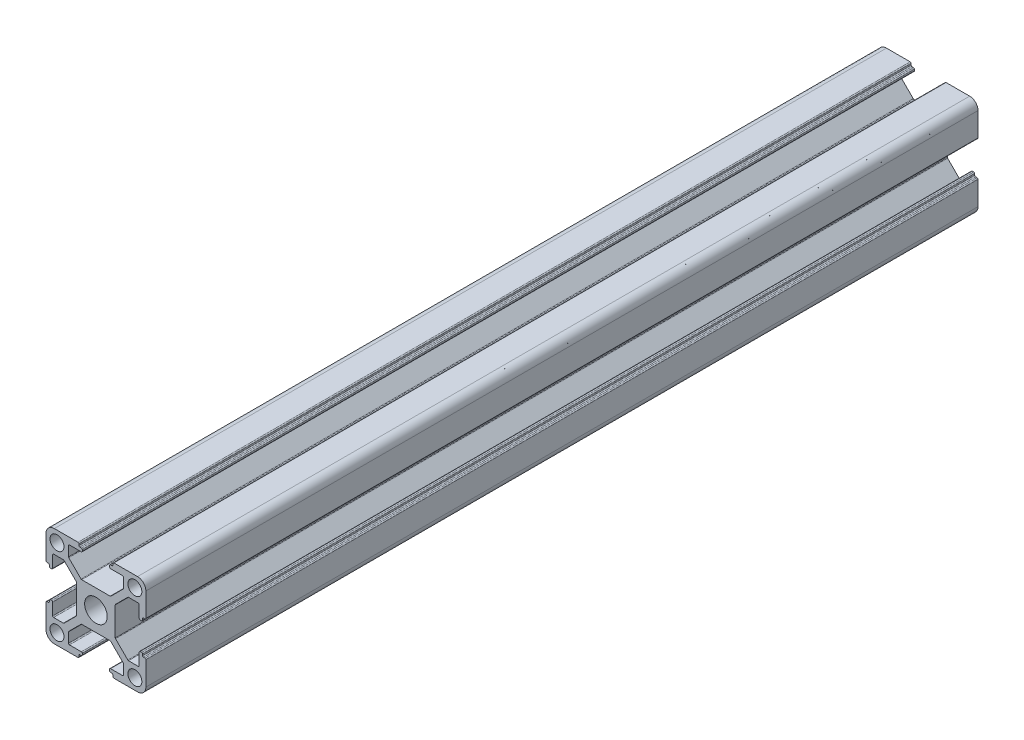
from build123d import *

# Parameters (mm, degrees)
CROQUIS1_R              = 2.1
CROQUIS1_R_2            = 3.4
SALIENTE_EXTRUIR1_DEPTH = 400
CROQUIS3_W              = 36.891585518
CROQUIS3_H              = 31.857253434
CORTAR_EXTRUIR2_DEPTH   = 150


with BuildPart() as part:
    # Croquis1 → Saliente-Extruir1 (new body)
    with BuildSketch(Plane(origin=(0, 0, -50), x_dir=(-1, 0, 0), z_dir=(0, 0, -1))):
        with BuildLine():
            Line((14.7, -5.1), (14.3, -5.1))
            ThreePointArc((14.3, -5.1), (14.087867966, -5.012132034), (14, -4.8))
            Line((14, -4.8), (14, -4.4))
            ThreePointArc((14, -4.4), (13.912132034, -4.187867966), (13.7, -4.1))
            Line((13.7, -4.1), (13.3, -4.1))
            ThreePointArc((13.3, -4.1), (13.087867966, -4.187867966), (13, -4.4))
            Line((13, -4.4), (13, -7.95))
            ThreePointArc((13, -7.95), (12.912132034, -8.162132034), (12.7, -8.25))
            Line((12.7, -8.25), (9.789264108, -8.25))
            ThreePointArc((9.789264108, -8.25), (9.674477865, -8.22717164), (9.577160832, -8.162160788))
            Line((9.577160832, -8.162160788), (5.887896723, -4.473896751))
            ThreePointArc((5.887896723, -4.473896751), (5.822843922, -4.376559778), (5.8, -4.261735963))
            Line((5.8, -4.261735963), (5.8, 4.260735931))
            ThreePointArc((5.8, 4.260735931), (5.82283614, 4.375540961), (5.887867966, 4.472867966))
            Line((5.887867966, 4.472867966), (9.577132034, 8.162132034))
            ThreePointArc((9.577132034, 8.162132034), (9.674459039, 8.22716386), (9.789264069, 8.25))
            Line((9.789264069, 8.25), (12.7, 8.25))
            ThreePointArc((12.7, 8.25), (12.912132034, 8.162132034), (13, 7.95))
            Line((13, 7.95), (13, 4.4))
            ThreePointArc((13, 4.4), (13.087867966, 4.187867966), (13.3, 4.1))
            Line((13.3, 4.1), (13.7, 4.1))
            ThreePointArc((13.7, 4.1), (13.912132034, 4.187867966), (14, 4.4))
            Line((14, 4.4), (14, 4.8))
            ThreePointArc((14, 4.8), (14.087867966, 5.012132034), (14.3, 5.1))
            Line((14.3, 5.1), (14.7, 5.1))
            ThreePointArc((14.7, 5.1), (14.912132034, 5.187867966), (15, 5.4))
            Line((15, 5.4), (15, 12.5))
            ThreePointArc((15, 12.5), (14.267766953, 14.267766953), (12.5, 15))
            Line((12.5, 15), (5.4, 15))
            ThreePointArc((5.4, 15), (5.187867966, 14.912132034), (5.1, 14.7))
            Line((5.1, 14.7), (5.1, 14.3))
            ThreePointArc((5.1, 14.3), (5.012132034, 14.087867966), (4.8, 14))
            Line((4.8, 14), (4.4, 14))
            ThreePointArc((4.4, 14), (4.187867966, 13.912132034), (4.1, 13.7))
            Line((4.1, 13.7), (4.1, 13.3))
            ThreePointArc((4.1, 13.3), (4.187867966, 13.087867966), (4.4, 13))
            Line((4.4, 13), (7.95, 13))
            ThreePointArc((7.95, 13), (8.162132034, 12.912132034), (8.25, 12.7))
            Line((8.25, 12.7), (8.25, 9.788264069))
            ThreePointArc((8.25, 9.788264069), (8.22716386, 9.673459039), (8.162132034, 9.576132034))
            Line((8.162132034, 9.576132034), (4.473867966, 5.887867966))
            ThreePointArc((4.473867966, 5.887867966), (4.376540961, 5.82283614), (4.261735931, 5.8))
            Line((4.261735931, 5.8), (-4.260735892, 5.8))
            ThreePointArc((-4.260735892, 5.8), (-4.375522135, 5.82282836), (-4.472839168, 5.887839212))
            Line((-4.472839168, 5.887839212), (-8.162103277, 9.576103249))
            ThreePointArc((-8.162103277, 9.576103249), (-8.227156078, 9.673440222), (-8.25, 9.788264037))
            Line((-8.25, 9.788264037), (-8.25, 12.7))
            ThreePointArc((-8.25, 12.7), (-8.162132034, 12.912132034), (-7.95, 13))
            Line((-7.95, 13), (-4.4, 13))
            ThreePointArc((-4.4, 13), (-4.187867966, 13.087867966), (-4.1, 13.3))
            Line((-4.1, 13.3), (-4.1, 13.7))
            ThreePointArc((-4.1, 13.7), (-4.187867966, 13.912132034), (-4.4, 14))
            Line((-4.4, 14), (-4.8, 14))
            ThreePointArc((-4.8, 14), (-5.012132034, 14.087867966), (-5.1, 14.3))
            Line((-5.1, 14.3), (-5.1, 14.7))
            ThreePointArc((-5.1, 14.7), (-5.187867966, 14.912132034), (-5.4, 15))
            Line((-5.4, 15), (-12.5, 15))
            ThreePointArc((-12.5, 15), (-14.267766953, 14.267766953), (-15, 12.5))
            Line((-15, 12.5), (-15, 5.4))
            ThreePointArc((-15, 5.4), (-14.912132034, 5.187867966), (-14.7, 5.1))
            Line((-14.7, 5.1), (-14.3, 5.1))
            ThreePointArc((-14.3, 5.1), (-14.087867966, 5.012132034), (-14, 4.8))
            Line((-14, 4.8), (-14, 4.4))
            ThreePointArc((-14, 4.4), (-13.912132034, 4.187867966), (-13.7, 4.1))
            Line((-13.7, 4.1), (-13.3, 4.1))
            ThreePointArc((-13.3, 4.1), (-13.087867966, 4.187867966), (-13, 4.4))
            Line((-13, 4.4), (-13, 7.95))
            ThreePointArc((-13, 7.95), (-12.912132034, 8.162132034), (-12.7, 8.25))
            Line((-12.7, 8.25), (-9.788264037, 8.25))
            ThreePointArc((-9.788264037, 8.25), (-9.673440222, 8.227156078), (-9.576103249, 8.162103277))
            Line((-9.576103249, 8.162103277), (-5.887839212, 4.472839168))
            ThreePointArc((-5.887839212, 4.472839168), (-5.82282836, 4.375522135), (-5.8, 4.260735892))
            Line((-5.8, 4.260735892), (-5.8, -4.261735931))
            ThreePointArc((-5.8, -4.261735931), (-5.82283614, -4.376540961), (-5.887867966, -4.473867966))
            Line((-5.887867966, -4.473867966), (-9.576132034, -8.162132034))
            ThreePointArc((-9.576132034, -8.162132034), (-9.673459039, -8.22716386), (-9.788264069, -8.25))
            Line((-9.788264069, -8.25), (-12.7, -8.25))
            ThreePointArc((-12.7, -8.25), (-12.912132034, -8.162132034), (-13, -7.95))
            Line((-13, -7.95), (-13, -4.4))
            ThreePointArc((-13, -4.4), (-13.087867966, -4.187867966), (-13.3, -4.1))
            Line((-13.3, -4.1), (-13.7, -4.1))
            ThreePointArc((-13.7, -4.1), (-13.912132034, -4.187867966), (-14, -4.4))
            Line((-14, -4.4), (-14, -4.8))
            ThreePointArc((-14, -4.8), (-14.087867966, -5.012132034), (-14.3, -5.1))
            Line((-14.3, -5.1), (-14.7, -5.1))
            ThreePointArc((-14.7, -5.1), (-14.912132034, -5.187867966), (-15, -5.4))
            Line((-15, -5.4), (-15, -12.5))
            ThreePointArc((-15, -12.5), (-14.267766953, -14.267766953), (-12.5, -15))
            Line((-12.5, -15), (-5.4, -15))
            ThreePointArc((-5.4, -15), (-5.187867966, -14.912132034), (-5.1, -14.7))
            Line((-5.1, -14.7), (-5.1, -14.3))
            ThreePointArc((-5.1, -14.3), (-5.012132034, -14.087867966), (-4.8, -14))
            Line((-4.8, -14), (-4.4, -14))
            ThreePointArc((-4.4, -14), (-4.187867966, -13.912132034), (-4.1, -13.7))
            Line((-4.1, -13.7), (-4.1, -13.3))
            ThreePointArc((-4.1, -13.3), (-4.187867966, -13.087867966), (-4.4, -13))
            Line((-4.4, -13), (-7.95, -13))
            ThreePointArc((-7.95, -13), (-8.162132034, -12.912132034), (-8.25, -12.7))
            Line((-8.25, -12.7), (-8.25, -9.789264069))
            ThreePointArc((-8.25, -9.789264069), (-8.22716386, -9.674459039), (-8.162132034, -9.577132034))
            Line((-8.162132034, -9.577132034), (-4.472867966, -5.887867966))
            ThreePointArc((-4.472867966, -5.887867966), (-4.375540961, -5.82283614), (-4.260735931, -5.8))
            Line((-4.260735931, -5.8), (4.261735963, -5.8))
            ThreePointArc((4.261735963, -5.8), (4.376559778, -5.822843922), (4.473896751, -5.887896723))
            Line((4.473896751, -5.887896723), (8.162160788, -9.577160832))
            ThreePointArc((8.162160788, -9.577160832), (8.22717164, -9.674477865), (8.25, -9.789264108))
            Line((8.25, -9.789264108), (8.25, -12.7))
            ThreePointArc((8.25, -12.7), (8.162132034, -12.912132034), (7.95, -13))
            Line((7.95, -13), (4.4, -13))
            ThreePointArc((4.4, -13), (4.187867966, -13.087867966), (4.1, -13.3))
            Line((4.1, -13.3), (4.1, -13.7))
            ThreePointArc((4.1, -13.7), (4.187867966, -13.912132034), (4.4, -14))
            Line((4.4, -14), (4.8, -14))
            ThreePointArc((4.8, -14), (5.012132034, -14.087867966), (5.1, -14.3))
            Line((5.1, -14.3), (5.1, -14.7))
            ThreePointArc((5.1, -14.7), (5.187867966, -14.912132034), (5.4, -15))
            Line((5.4, -15), (12.5, -15))
            ThreePointArc((12.5, -15), (14.267766953, -14.267766953), (15, -12.5))
            Line((15, -12.5), (15, -5.4))
            ThreePointArc((15, -5.4), (14.912132034, -5.187867966), (14.7, -5.1))
        make_face()
        with Locations((-11.7, 11.7)):
            Circle(CROQUIS1_R, mode=Mode.SUBTRACT)
        with Locations((-11.7, -11.7)):
            Circle(CROQUIS1_R, mode=Mode.SUBTRACT)
        Circle(CROQUIS1_R_2, mode=Mode.SUBTRACT)
        with Locations((11.7, 11.7)):
            Circle(CROQUIS1_R, mode=Mode.SUBTRACT)
        with Locations((11.7, -11.7)):
            Circle(CROQUIS1_R, mode=Mode.SUBTRACT)
    extrude(amount=-SALIENTE_EXTRUIR1_DEPTH)

    # Croquis3 → Cortar-Extruir2 (cut)
    with BuildSketch(Plane(origin=(0, 0, -50), x_dir=(-1, 0, 0), z_dir=(0, 0, -1))):
        with Locations((0.583982522, 0.302059925)):
            Rectangle(CROQUIS3_W, CROQUIS3_H)
    extrude(amount=-CORTAR_EXTRUIR2_DEPTH, mode=Mode.SUBTRACT)


solid = part.part
